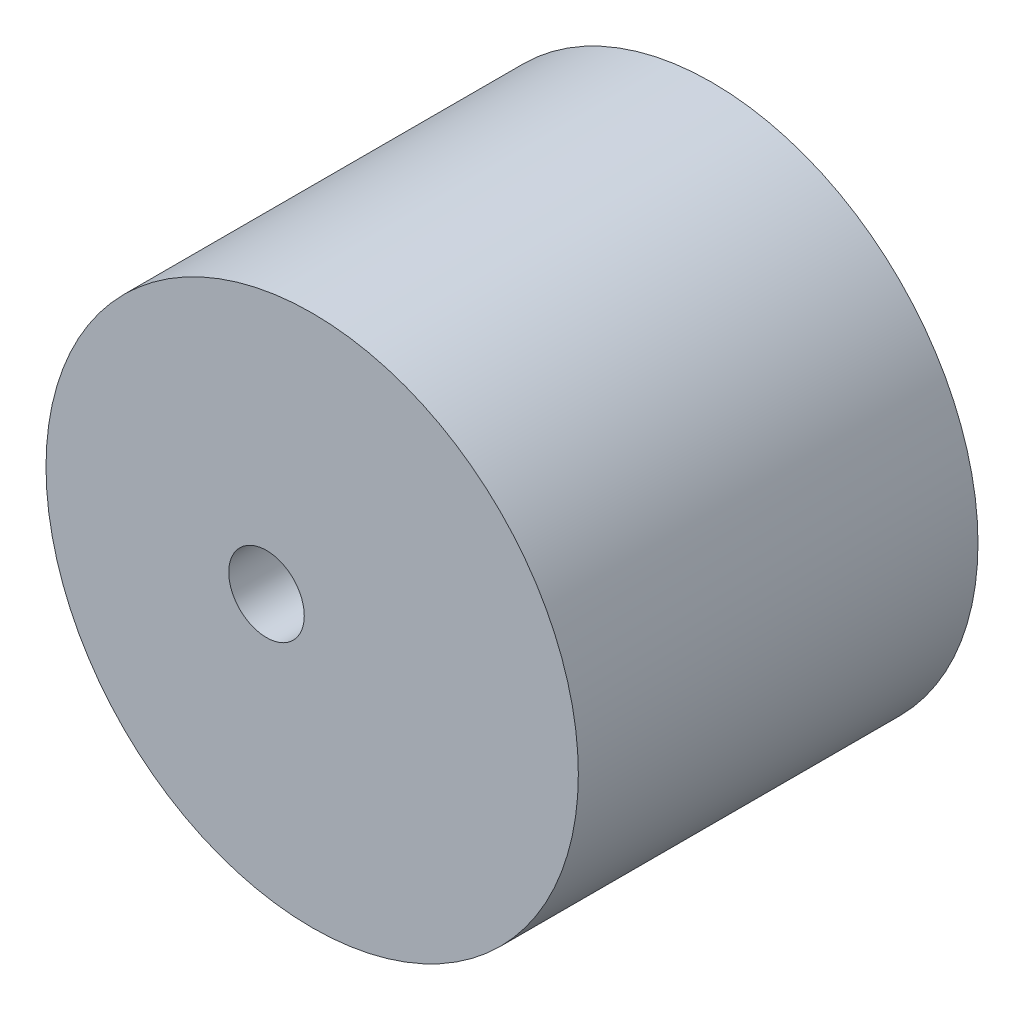
from build123d import *

# Parameters (mm, degrees)
SKETCH11_R           = 23.310625
SKETCH11_R_2         = 3.3085
BOSS_EXTRUDE13_DEPTH = 35


with BuildPart() as part:
    # Sketch11 → Boss-Extrude13 (new body)
    with BuildSketch(Plane.XY):
        Circle(SKETCH11_R)
        with Locations((-4, 0)):
            Circle(SKETCH11_R_2, mode=Mode.SUBTRACT)
    extrude(amount=BOSS_EXTRUDE13_DEPTH)


solid = part.part
